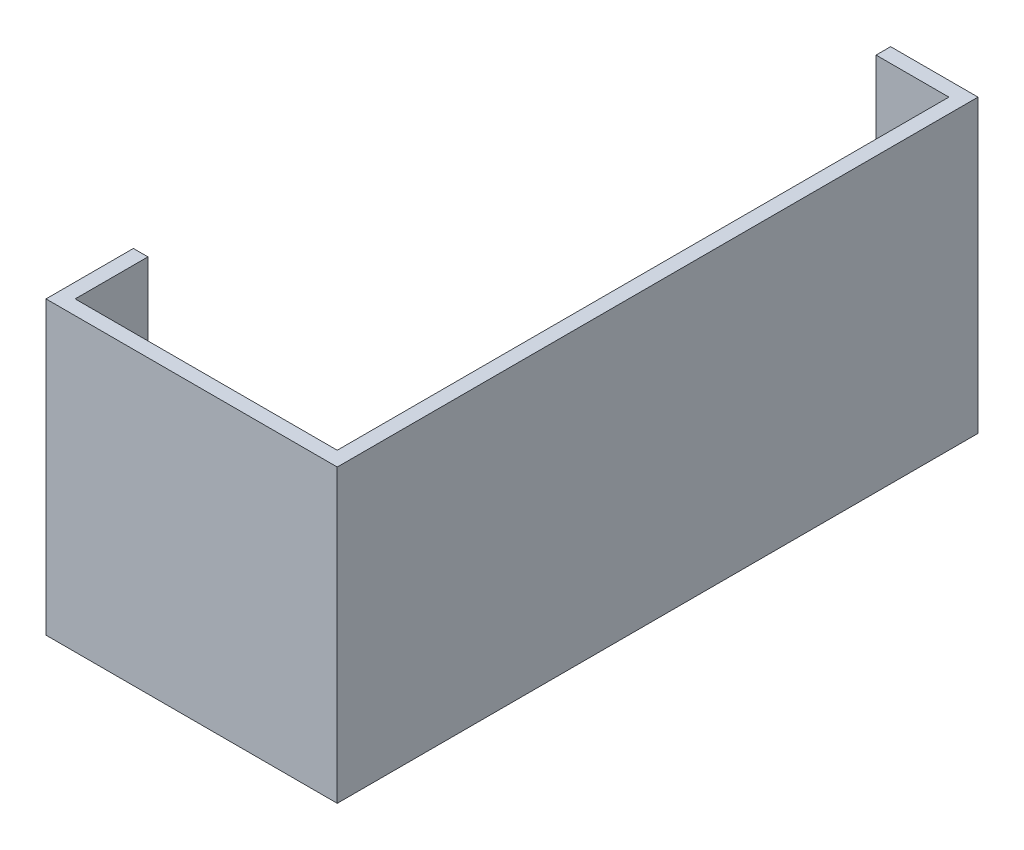
from build123d import *

# Parameters (mm, degrees)
ESTRUSIONE_ESTRUSIONE1_DEPTH = 100
ESTRUSIONE_ESTRUSIONE2_DEPTH = 3


with BuildPart() as part:
    # Schizzo1 → Estrusione-Estrusione1 (new body)
    with BuildSketch(Plane(origin=(0, 0, 0), x_dir=(1, 0, 0), z_dir=(0, 1, 0))):
        Polygon((-100, 0), (0, 0), (0, 220), (-30, 220), (-30, 215), (-5, 215), (-5, 5), (-95, 5), (-95, 30), (-100, 30), align=None)
    extrude(amount=ESTRUSIONE_ESTRUSIONE1_DEPTH)

    # Schizzo2 → Estrusione-Estrusione2 (add)
    with BuildSketch(Plane.XZ):
        Polygon((-30, -215), (-5, -215), (-5, -5), (-95, -5), (-95, -30), align=None)
    extrude(amount=-ESTRUSIONE_ESTRUSIONE2_DEPTH)


solid = part.part
